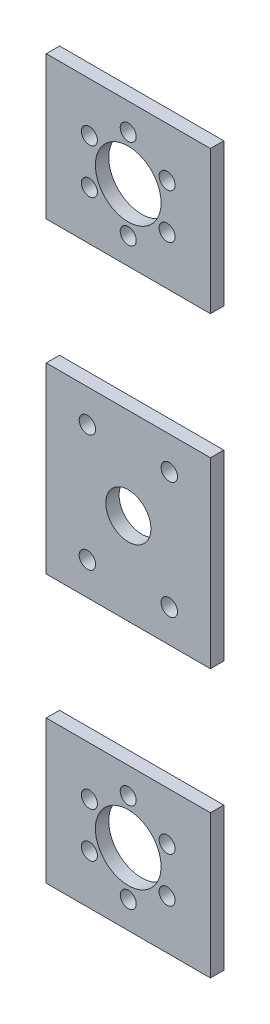
from build123d import *

# Parameters (mm, degrees)
SKETCH2_W           = 80
SKETCH2_H           = 350
BOSS_EXTRUDE1_DEPTH = 6.5
SKETCH3_R           = 11
SKETCH3_R_2         = 16
SKETCH3_R_3         = 3.9
SKETCH3_R_4         = 4
CUT_EXTRUDE1_DEPTH  = 7.5
CUT_EXTRUDE2_DEPTH  = 7.5


with BuildPart() as part:
    # Sketch2 → Boss-Extrude1 (new body)
    with BuildSketch(Plane.XY):
        Rectangle(SKETCH2_W, SKETCH2_H)
    extrude(amount=BOSS_EXTRUDE1_DEPTH)

    # Sketch3 → Cut-Extrude1 (cut, through all)
    with BuildSketch(Plane.XY.offset(6.5)):
        Circle(SKETCH3_R)
        with Locations((-0.047536851, 140)):
            Circle(SKETCH3_R_2)
        with Locations((-0.047536851, -140)):
            Circle(SKETCH3_R_2)
        with Locations((-0.047536851, 118.130030835)):
            Circle(SKETCH3_R_3)
        with Locations((-18.987485728, 129.065015417)):
            Circle(SKETCH3_R_3)
        with Locations((-18.987485728, 150.934984583)):
            Circle(SKETCH3_R_3)
        with Locations((-0.047536851, 161.869969165)):
            Circle(SKETCH3_R_3)
        with Locations((18.892412027, 150.934984583)):
            Circle(SKETCH3_R_3)
        with Locations((18.892412027, 129.065015417)):
            Circle(SKETCH3_R_3)
        with Locations((18.892412027, -129.065015417)):
            Circle(SKETCH3_R_3)
        with Locations((18.892412027, -150.934984583)):
            Circle(SKETCH3_R_3)
        with Locations((-0.047536851, -161.869969165)):
            Circle(SKETCH3_R_3)
        with Locations((-18.987485728, -150.934984583)):
            Circle(SKETCH3_R_3)
        with Locations((-18.987485728, -129.065015417)):
            Circle(SKETCH3_R_3)
        with Locations((-0.047536851, -118.130030835)):
            Circle(SKETCH3_R_3)
        with Locations((19.950260187, 28.512090355)):
            Circle(SKETCH3_R_4)
        with Locations((-19.950260187, 28.498542176)):
            Circle(SKETCH3_R_4)
        with Locations((19.950260187, -28.525638534)):
            Circle(SKETCH3_R_4)
        with Locations((-19.950260187, -28.512090355)):
            Circle(SKETCH3_R_4)
    extrude(amount=-CUT_EXTRUDE1_DEPTH, mode=Mode.SUBTRACT)

    # Sketch4 → Cut-Extrude2 (cut, through all)
    with BuildSketch(Plane.XY.offset(6.5)):
        Polygon((-68.864439422, 44.514191981), (-41.075494308, 44.514191981), (41.075494308, 44.514191981), (68.816902572, 44.514191981), (68.816902572, 105.285938424), (-68.864439422, 105.285938424), align=None)
        Polygon((41.075494308, -44.514191981), (-41.075494308, -44.514191981), (-68.864439422, -44.514191981), (-68.864439422, -105.285938424), (68.816902572, -105.285938424), (68.816902572, -44.514191981), align=None)
    extrude(amount=-CUT_EXTRUDE2_DEPTH, mode=Mode.SUBTRACT)


solid = part.part
